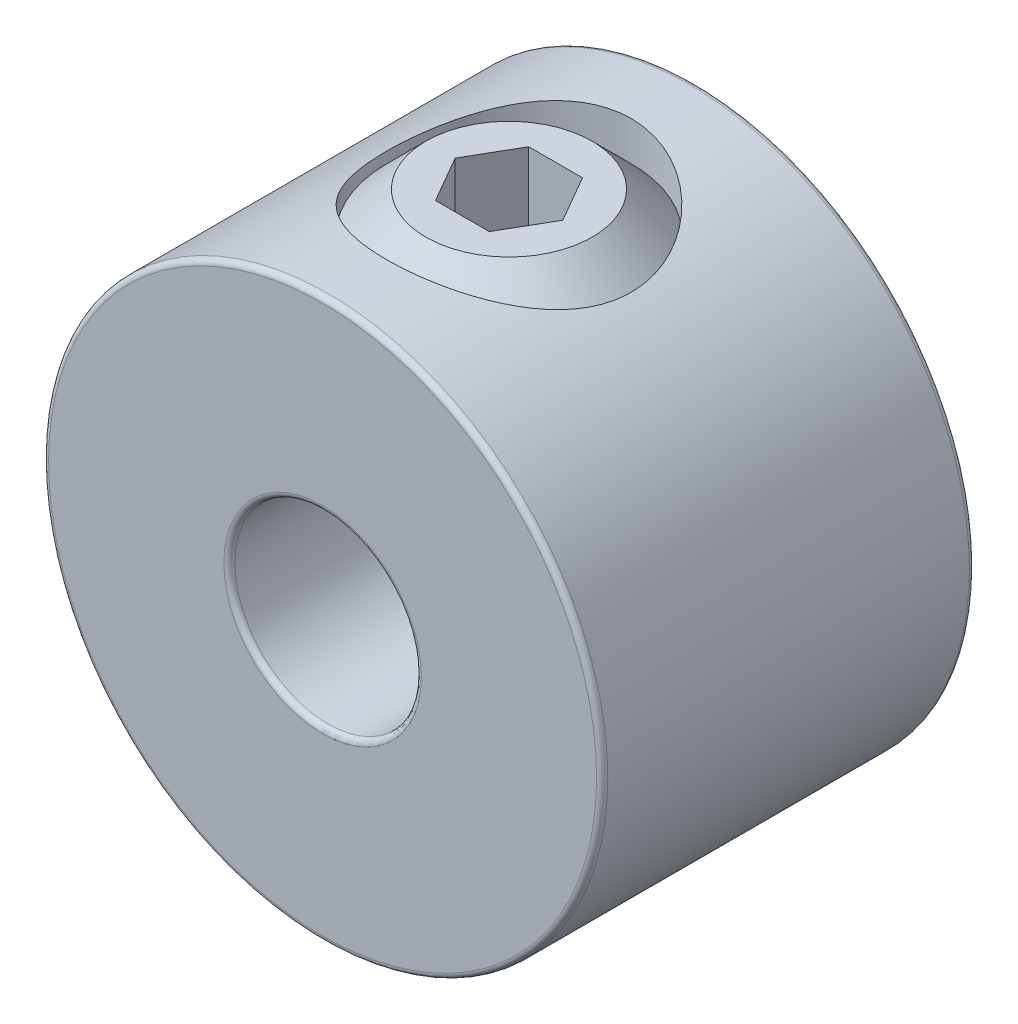
from build123d import *

# Parameters (mm, degrees)
SKETCH1_R          = 4.7625
SKETCH1_R_2        = 1.5875
EXTRUDE1_DEPTH     = 3.175
SKETCH2_R          = 2.0828
CUT_EXTRUDE1_DEPTH = 5.7625
FILLET1_R          = 0.09525
CUT_EXTRUDE2_DEPTH = 1.5875


with BuildPart() as part:
    # Sketch1 → Extrude1 (new body, symmetric)
    with BuildSketch(Plane.XY):
        Circle(SKETCH1_R)
        Circle(SKETCH1_R_2, mode=Mode.SUBTRACT)
    extrude(amount=EXTRUDE1_DEPTH, both=True)

    # Sketch2 → Cut-Extrude1 (cut, through all)
    with BuildSketch(Plane(origin=(41.275, 0, 0), x_dir=(0, 0, -1), z_dir=(0, -1, 0))):
        with Locations((0, -41.275)):
            Circle(SKETCH2_R)
    extrude(amount=-CUT_EXTRUDE1_DEPTH, mode=Mode.SUBTRACT)

    # Fillet1
    fillet1_edges = [part.edges().sort_by_distance(p)[0] for p in [
        (-4.7625, 0, -3.175),
        (-4.7625, 0, 3.175),
        (-1.5875, 0, -3.175),
        (-1.5875, 0, 3.175),
    ]]
    fillet(fillet1_edges, radius=FILLET1_R)


with BuildPart() as body_2:
    # Sketch3 → Revolve1 (revolve)
    with BuildSketch(Plane.XY):
        Polygon((-1.416367744, 1.5875), (-0.799718707, 1.5875), (0, 2.387218707), (0, 4.7625), (-1.416367744, 4.7625), (-2.0828, 4.096067744), (-2.0828, 2.253932256), align=None)
    revolve(axis=Axis((0, 1.5875, 0), (0, -1, 0)))

    # Sketch4 → Cut-Extrude2 (cut)
    with BuildSketch(Plane(origin=(3.3734375, 4.7625, 0), x_dir=(0, 0, -1), z_dir=(0, -1, 0))):
        Polygon((0, -2.456893948), (-0.79375, -2.915165724), (-0.79375, -3.831709276), (0, -4.289981052), (0.79375, -3.831709276), (0.79375, -2.915165724), align=None)
    extrude(amount=CUT_EXTRUDE2_DEPTH, mode=Mode.SUBTRACT)


solid = Compound([part.part, body_2.part])
